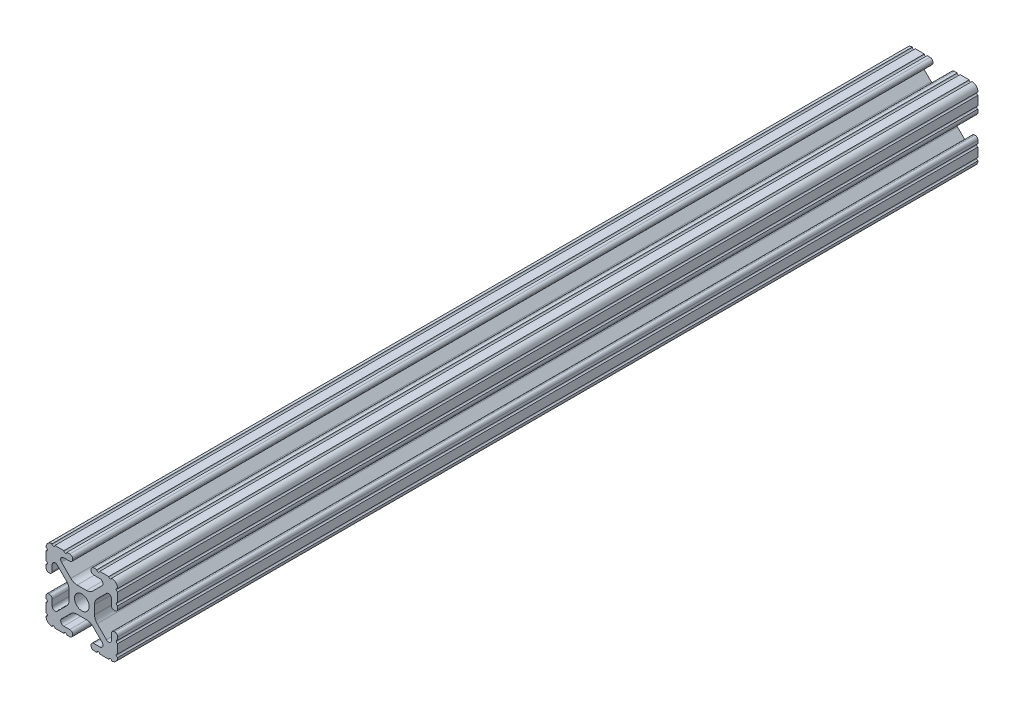
from build123d import *

# Parameters (mm, degrees)
SKETCH1_R           = 2.6035
BOSS_EXTRUDE1_DEPTH = 305


with BuildPart() as part:
    # Sketch1 → Boss-Extrude1 (new body)
    with BuildSketch(Plane.XY):
        with BuildLine():
            Line((-7.179650497, -8.645192506), (-3.952270251, -5.423690499))
            ThreePointArc((-3.952270251, -5.423690499), (-2.922936451, -4.736929036), (-1.709253557, -4.4958))
            Line((-1.709253557, -4.4958), (1.709253557, -4.4958))
            ThreePointArc((1.709253557, -4.4958), (2.922936451, -4.736929036), (3.952270251, -5.423690499))
            Line((3.952270251, -5.423690499), (7.179650497, -8.645192506))
            ThreePointArc((7.179650497, -8.645192506), (7.41473083, -9.822813117), (6.416408329, -10.4902))
            Line((6.416408329, -10.4902), (4.287512407, -10.4902))
            ThreePointArc((4.287512407, -10.4902), (3.54574862, -10.79744862), (3.2385, -11.539212407))
            Line((3.2385, -11.539212407), (3.2385, -11.650987593))
            ThreePointArc((3.2385, -11.650987593), (3.54574862, -12.39275138), (4.287512407, -12.7))
            Line((4.287512407, -12.7), (5.317126718, -12.7))
            ThreePointArc((5.317126718, -12.7), (5.825126718, -12.192), (6.333126718, -12.7))
            Line((6.333126718, -12.7), (9.550443118, -12.7))
            ThreePointArc((9.550443118, -12.7), (10.058366869, -12.192000006), (10.566443095, -12.699847501))
            ThreePointArc((10.566443095, -12.699847501), (12.082537762, -12.08250727), (12.699846982, -10.566399977))
            ThreePointArc((12.699846982, -10.566399977), (12.192000006, -10.058323491), (12.7, -9.5504))
            Line((12.7, -9.5504), (12.7, -6.3330836))
            ThreePointArc((12.7, -6.3330836), (12.192, -5.8250836), (12.7, -5.3170836))
            Line((12.7, -5.3170836), (12.7, -4.287469289))
            ThreePointArc((12.7, -4.287469289), (12.39275138, -3.545705502), (11.650987593, -3.238456882))
            Line((11.650987593, -3.238456882), (11.539212407, -3.238456882))
            ThreePointArc((11.539212407, -3.238456882), (10.79744862, -3.545705502), (10.4902, -4.287469289))
            Line((10.4902, -4.287469289), (10.4902, -6.402089023))
            ThreePointArc((10.4902, -6.402089023), (9.856505071, -7.351067942), (8.737131347, -7.129408934))
            Line((8.737131347, -7.129408934), (5.441005833, -3.840816462))
            ThreePointArc((5.441005833, -3.840816462), (4.750877967, -2.809883091), (4.5085, -1.593185507))
            Line((4.5085, -1.593185507), (4.5085, 1.593185507))
            ThreePointArc((4.5085, 1.593185507), (4.750877967, 2.809883091), (5.441005833, 3.840816462))
            Line((5.441005833, 3.840816462), (8.737131347, 7.129408934))
            ThreePointArc((8.737131347, 7.129408934), (9.856505071, 7.351067942), (10.4902, 6.402089023))
            Line((10.4902, 6.402089023), (10.4902, 4.287469289))
            ThreePointArc((10.4902, 4.287469289), (10.79744862, 3.545705502), (11.539212407, 3.238456882))
            Line((11.539212407, 3.238456882), (11.650987593, 3.238456882))
            ThreePointArc((11.650987593, 3.238456882), (12.39275138, 3.545705502), (12.7, 4.287469289))
            Line((12.7, 4.287469289), (12.7, 5.3170836))
            ThreePointArc((12.7, 5.3170836), (12.192, 5.8250836), (12.7, 6.3330836))
            Line((12.7, 6.3330836), (12.7, 9.5504))
            ThreePointArc((12.7, 9.5504), (12.192000006, 10.058323491), (12.699846982, 10.566399977))
            ThreePointArc((12.699846982, 10.566399977), (12.082537762, 12.08250727), (10.566443095, 12.699847501))
            ThreePointArc((10.566443095, 12.699847501), (10.058366869, 12.192000006), (9.550443118, 12.7))
            Line((9.550443118, 12.7), (6.333126718, 12.7))
            ThreePointArc((6.333126718, 12.7), (5.825126718, 12.192), (5.317126718, 12.7))
            Line((5.317126718, 12.7), (4.287512407, 12.7))
            ThreePointArc((4.287512407, 12.7), (3.54574862, 12.39275138), (3.2385, 11.650987593))
            Line((3.2385, 11.650987593), (3.2385, 11.539212407))
            ThreePointArc((3.2385, 11.539212407), (3.54574862, 10.79744862), (4.287512407, 10.4902))
            Line((4.287512407, 10.4902), (6.476788598, 10.4902))
            ThreePointArc((6.476788598, 10.4902), (7.432222385, 9.85140422), (7.207036008, 8.724370562))
            Line((7.207036008, 8.724370562), (3.898272566, 5.423169045))
            ThreePointArc((3.898272566, 5.423169045), (2.869120213, 4.736787962), (1.655778399, 4.4958))
            Line((1.655778399, 4.4958), (-1.655778399, 4.4958))
            ThreePointArc((-1.655778399, 4.4958), (-2.869120213, 4.736787962), (-3.898272566, 5.423169045))
            Line((-3.898272566, 5.423169045), (-7.207036008, 8.724370562))
            ThreePointArc((-7.207036008, 8.724370562), (-7.432222385, 9.85140422), (-6.476788598, 10.4902))
            Line((-6.476788598, 10.4902), (-4.287512407, 10.4902))
            ThreePointArc((-4.287512407, 10.4902), (-3.54574862, 10.79744862), (-3.2385, 11.539212407))
            Line((-3.2385, 11.539212407), (-3.2385, 11.650987593))
            ThreePointArc((-3.2385, 11.650987593), (-3.54574862, 12.39275138), (-4.287512407, 12.7))
            Line((-4.287512407, 12.7), (-5.317126718, 12.7))
            ThreePointArc((-5.317126718, 12.7), (-5.825126718, 12.192), (-6.333126718, 12.7))
            Line((-6.333126718, 12.7), (-9.550443118, 12.7))
            ThreePointArc((-9.550443118, 12.7), (-10.058366869, 12.192000006), (-10.566443095, 12.699847501))
            ThreePointArc((-10.566443095, 12.699847501), (-12.082537762, 12.08250727), (-12.699846982, 10.566399977))
            ThreePointArc((-12.699846982, 10.566399977), (-12.192000006, 10.058323491), (-12.7, 9.5504))
            Line((-12.7, 9.5504), (-12.7, 6.3330836))
            ThreePointArc((-12.7, 6.3330836), (-12.192, 5.8250836), (-12.7, 5.3170836))
            Line((-12.7, 5.3170836), (-12.7, 4.287469289))
            ThreePointArc((-12.7, 4.287469289), (-12.39275138, 3.545705502), (-11.650987593, 3.238456882))
            Line((-11.650987593, 3.238456882), (-11.539212407, 3.238456882))
            ThreePointArc((-11.539212407, 3.238456882), (-10.79744862, 3.545705502), (-10.4902, 4.287469289))
            Line((-10.4902, 4.287469289), (-10.4902, 6.402089023))
            ThreePointArc((-10.4902, 6.402089023), (-9.856505071, 7.351067942), (-8.737131347, 7.129408934))
            Line((-8.737131347, 7.129408934), (-5.441005833, 3.840816462))
            ThreePointArc((-5.441005833, 3.840816462), (-4.750877967, 2.809883091), (-4.5085, 1.593185507))
            Line((-4.5085, 1.593185507), (-4.5085, -1.593185507))
            ThreePointArc((-4.5085, -1.593185507), (-4.750877967, -2.809883091), (-5.441005833, -3.840816462))
            Line((-5.441005833, -3.840816462), (-8.737131347, -7.129408934))
            ThreePointArc((-8.737131347, -7.129408934), (-9.856505071, -7.351067942), (-10.4902, -6.402089023))
            Line((-10.4902, -6.402089023), (-10.4902, -4.287469289))
            ThreePointArc((-10.4902, -4.287469289), (-10.79744862, -3.545705502), (-11.539212407, -3.238456882))
            Line((-11.539212407, -3.238456882), (-11.650987593, -3.238456882))
            ThreePointArc((-11.650987593, -3.238456882), (-12.39275138, -3.545705502), (-12.7, -4.287469289))
            Line((-12.7, -4.287469289), (-12.7, -5.3170836))
            ThreePointArc((-12.7, -5.3170836), (-12.192, -5.8250836), (-12.7, -6.3330836))
            Line((-12.7, -6.3330836), (-12.7, -9.5504))
            ThreePointArc((-12.7, -9.5504), (-12.192000006, -10.058323491), (-12.699846982, -10.566399977))
            ThreePointArc((-12.699846982, -10.566399977), (-12.082537762, -12.08250727), (-10.566443095, -12.699847501))
            ThreePointArc((-10.566443095, -12.699847501), (-10.058366869, -12.192000006), (-9.550443118, -12.7))
            Line((-9.550443118, -12.7), (-6.333126718, -12.7))
            ThreePointArc((-6.333126718, -12.7), (-5.825126718, -12.192), (-5.317126718, -12.7))
            Line((-5.317126718, -12.7), (-4.287512407, -12.7))
            ThreePointArc((-4.287512407, -12.7), (-3.54574862, -12.39275138), (-3.2385, -11.650987593))
            Line((-3.2385, -11.650987593), (-3.2385, -11.539212407))
            ThreePointArc((-3.2385, -11.539212407), (-3.54574862, -10.79744862), (-4.287512407, -10.4902))
            Line((-4.287512407, -10.4902), (-6.416408329, -10.4902))
            ThreePointArc((-6.416408329, -10.4902), (-7.41473083, -9.822813117), (-7.179650497, -8.645192506))
        make_face()
        Circle(SKETCH1_R, mode=Mode.SUBTRACT)
    extrude(amount=BOSS_EXTRUDE1_DEPTH)


solid = part.part
